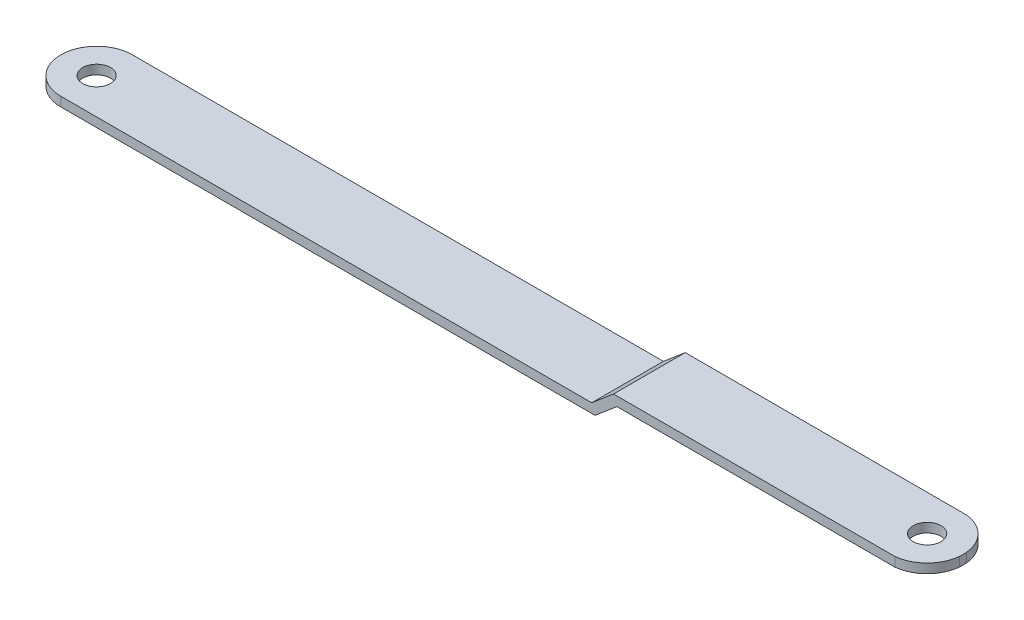
from build123d import *

# Parameters (mm, degrees)
EXTRUDE_1_DEPTH     = 15.5
SKETCH_2_OUTSIDE_W  = 236.142
SKETCH_2_OUTSIDE_H  = 56.642
SKETCH_2_OUTSIDE_R  = 3
CUT_EXTRUDE_4_DEPTH = 10


with BuildPart() as part:
    # Эскиз1 → Вытянуть-Тонкостенный1 (new body)
    with BuildSketch(Plane.XY):
        Polygon((0, 0), (122.5, 0), (127.219413382, 4), (195, 4), (195, 2), (127.952959941, 2), (123.233546559, -2), (0, -2), align=None)
    extrude(amount=EXTRUDE_1_DEPTH)

    # Эскиз2 outside → Вырез-Вытянуть4 (cut)
    with BuildSketch(Plane(origin=(0, 4, 0), x_dir=(1, 0, 0), z_dir=(0, 1, 0))):
        with Locations((97.5, -7.75)):
            Rectangle(SKETCH_2_OUTSIDE_W, SKETCH_2_OUTSIDE_H)
        with BuildLine():
            Line((188.022623145, 0), (7.75, 0))
            ThreePointArc((7.75, 0), (0, -7.75), (7.75, -15.5))
            Line((7.75, -15.5), (188.022623145, -15.5))
            ThreePointArc((188.022623145, -15.5), (195.03841746, -7.75), (188.022623145, 0))
        make_face(mode=Mode.SUBTRACT)
        with Locations((187.25, -7.75)):
            Circle(SKETCH_2_OUTSIDE_R)
        with Locations((7.75, -7.75)):
            Circle(SKETCH_2_OUTSIDE_R)
    extrude(amount=-CUT_EXTRUDE_4_DEPTH, mode=Mode.SUBTRACT)


solid = part.part
